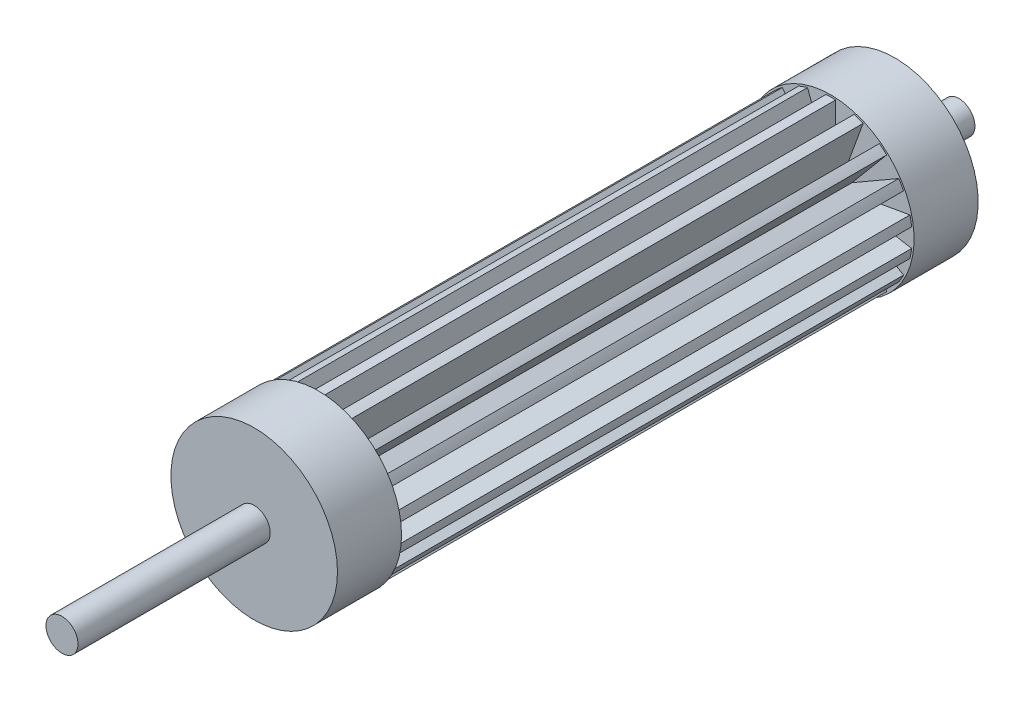
from build123d import *

# Parameters (mm, degrees)
SKETCH1_R                = 6.35
BOSS_EXTRUDE1_DEPTH      = 300
SKETCH2_W                = 3
SKETCH2_H                = 101.6
BOSS_EXTRUDE2_DEPTH      = 300
CIRPATTERN1_COUNT        = 9
SKETCH9_R                = 60.024928634
SKETCH9_R_2              = 25.4
CUT_EXTRUDE1_DEPTH       = 317.2
SKETCH11_W               = 209.953471272
SKETCH11_H               = 400
CUT_EXTRUDE2_DEPTH       = 158.6
SKETCH13_R               = 5
BOSS_EXTRUDE3_DEPTH      = 260
BOSS_EXTRUDE3_DEPTH_BACK = 20
SKETCH14_R               = 26
BOSS_EXTRUDE4_DEPTH      = 20
SKETCH15_R               = 26
BOSS_EXTRUDE5_DEPTH      = 20


with BuildPart() as part:
    # Sketch1 → Boss-Extrude1 (new body)
    with BuildSketch(Plane.XY):
        Circle(SKETCH1_R)
    extrude(amount=BOSS_EXTRUDE1_DEPTH)

    # Sketch2 → Boss-Extrude2 (add, through all)
    with BuildSketch(Plane.XY.offset(300)):
        Rectangle(SKETCH2_W, SKETCH2_H)
    boss_extrude2 = extrude(amount=-BOSS_EXTRUDE2_DEPTH)

    # CirPattern1: Boss-Extrude2 ×9 about axis
    cirpattern1_axis = Axis((0, 0, 0), (0, 0, 1))
    for i in range(1, CIRPATTERN1_COUNT):
        add(boss_extrude2.rotate(cirpattern1_axis, i * 360 / CIRPATTERN1_COUNT))

    # Sketch9 → Cut-Extrude1 (cut)
    with BuildSketch(Plane.XY.offset(300)):
        Circle(SKETCH9_R)
        Circle(SKETCH9_R_2, mode=Mode.SUBTRACT)
    extrude(amount=-CUT_EXTRUDE1_DEPTH, mode=Mode.SUBTRACT)

    # Sketch11 → Cut-Extrude2 (cut, symmetric)
    with BuildSketch(Plane(origin=(0, 0, 0), x_dir=(1, 0, 0), z_dir=(0, 1, 0))):
        with Locations((-1.595391119, -400)):
            Rectangle(SKETCH11_W, SKETCH11_H)
    extrude(amount=CUT_EXTRUDE2_DEPTH, both=True, mode=Mode.SUBTRACT)

    # Sketch13 → Boss-Extrude3 (add, two sides)
    with BuildSketch(Plane.XY) as boss_extrude3_sk:
        Circle(SKETCH13_R)
    extrude(amount=BOSS_EXTRUDE3_DEPTH)
    extrude(boss_extrude3_sk.sketch, amount=-BOSS_EXTRUDE3_DEPTH_BACK)

    # Sketch14 → Boss-Extrude4 (add)
    with BuildSketch(Plane(origin=(0, 0, 0), x_dir=(-1, 0, 0), z_dir=(0, 0, -1))):
        Circle(SKETCH14_R)
    extrude(amount=-BOSS_EXTRUDE4_DEPTH)

    # Sketch15 → Boss-Extrude5 (add)
    with BuildSketch(Plane.XY.offset(200)):
        Circle(SKETCH15_R)
    extrude(amount=-BOSS_EXTRUDE5_DEPTH)


solid = part.part
